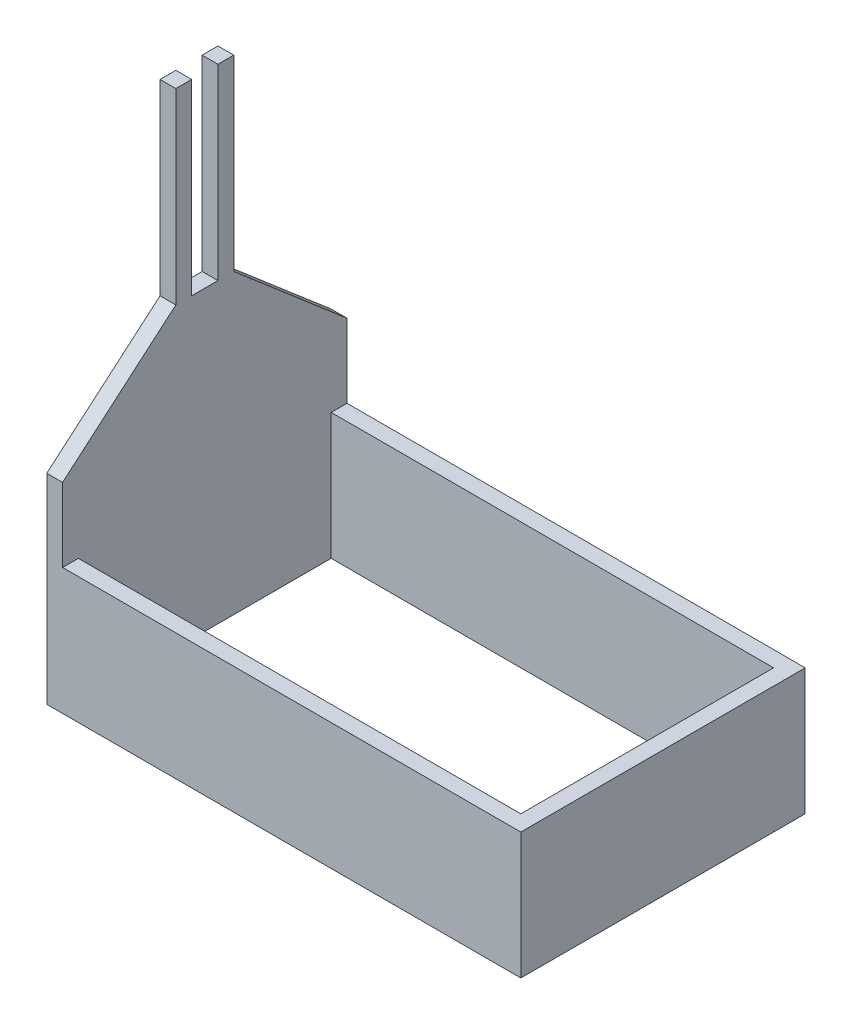
from build123d import *

# Parameters (mm, degrees)
SKETCH1_W               = 2286
SKETCH1_H               = 1371.6
BOSS_EXTRUDE1_DEPTH     = 609.6
SKETCH2_W               = 2133.6
SKETCH2_H               = 1219.2
CUT_EXTRUDE1_DEPTH      = 609.6
SKETCH3_W               = 76.2
SKETCH3_H               = 1371.6
BOSS_EXTRUDE3_DEPTH     = 1727.2
CUT_EXTRUDE2_DEPTH      = 1
CUT_EXTRUDE2_DEPTH_BACK = 1727.2
CUT_EXTRUDE3_DEPTH      = 1
CUT_EXTRUDE3_DEPTH_BACK = 1727.2


with BuildPart() as part:
    # Sketch1 → Boss-Extrude1 (new body)
    with BuildSketch(Plane(origin=(0, 0, 0), x_dir=(1, 0, 0), z_dir=(0, 1, 0))):
        with Locations((1143, 685.8)):
            Rectangle(SKETCH1_W, SKETCH1_H)
    extrude(amount=BOSS_EXTRUDE1_DEPTH)

    # Sketch2 → Cut-Extrude1 (cut)
    with BuildSketch(Plane(origin=(0, 609.6, 0), x_dir=(1, 0, 0), z_dir=(0, 1, 0))):
        with Locations((1143, 685.8)):
            Rectangle(SKETCH2_W, SKETCH2_H)
    extrude(amount=-CUT_EXTRUDE1_DEPTH, mode=Mode.SUBTRACT)

    # Sketch3 → Boss-Extrude3 (add)
    with BuildSketch(Plane(origin=(0, 609.6, 0), x_dir=(1, 0, 0), z_dir=(0, 1, 0))):
        with Locations((38.1, 685.8)):
            Rectangle(SKETCH3_W, SKETCH3_H)
    extrude(amount=BOSS_EXTRUDE3_DEPTH)

    # Sketch4 → Cut-Extrude2 (cut, two sides)
    with BuildSketch(Plane.ZY) as cut_extrude2_sk:
        Polygon((-5142.706542047, -2266.9631031), (-1371.6, 965.114607179), (-825.5, 1433.15697562), (-825.5, 2336.8), (-825.5, 7303.445837661), (-9880.152979292, 11387.995131231), (-14197.359521339, 1817.58619047), align=None)
    extrude(amount=CUT_EXTRUDE2_DEPTH, mode=Mode.SUBTRACT)
    extrude(cut_extrude2_sk.sketch, amount=-CUT_EXTRUDE2_DEPTH_BACK, mode=Mode.SUBTRACT)

    # Sketch5 → Cut-Extrude3 (cut, two sides)
    with BuildSketch(Plane.ZY) as cut_extrude3_sk:
        Polygon((-5792.145837661, 2336.8), (-825.5, 2336.8), (-749.3, 2336.8), (-749.3, 1433.15697562), (-622.3, 1433.15697562), (-622.3, 2336.8), (-546.1, 2336.8), (-546.1, 1433.15697562), (0, 965.114607179), (3771.106542047, -2266.9631031), (8079.741765722, 6683.229409707), (-1483.510613985, 11286.992512807), align=None)
    extrude(amount=CUT_EXTRUDE3_DEPTH, mode=Mode.SUBTRACT)
    extrude(cut_extrude3_sk.sketch, amount=-CUT_EXTRUDE3_DEPTH_BACK, mode=Mode.SUBTRACT)


solid = part.part
